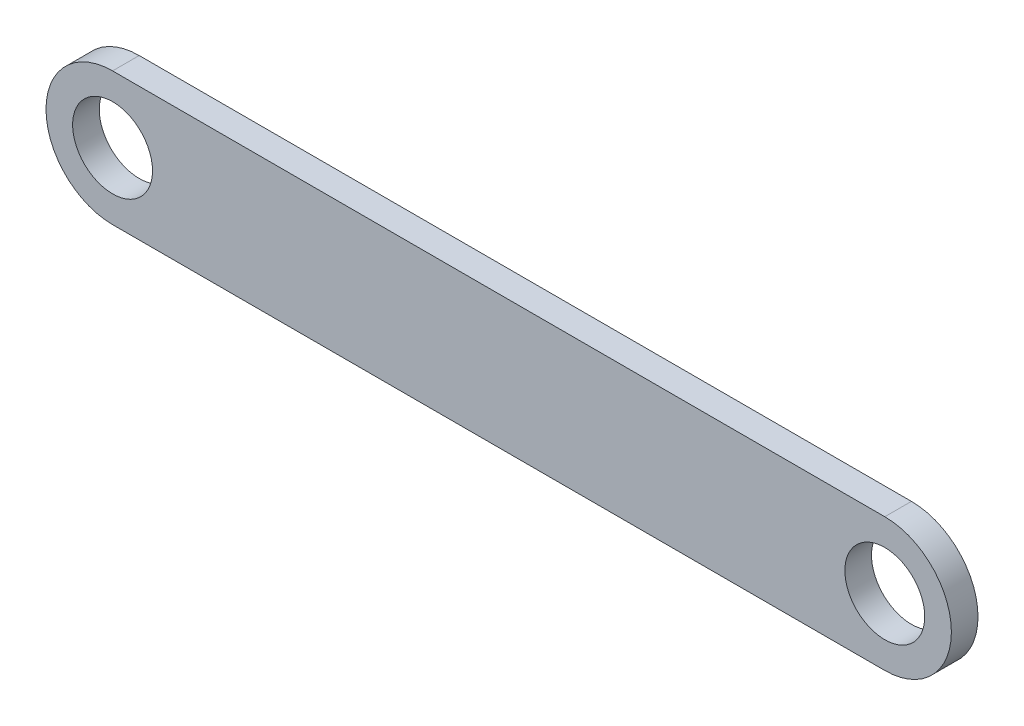
from build123d import *

# Parameters (mm, degrees)
SKETCH1_R           = 7.5
BOSS_EXTRUDE1_DEPTH = 2.5


with BuildPart() as part:
    # Sketch1 → Boss-Extrude1 (new body, symmetric)
    with BuildSketch(Plane.XY):
        with BuildLine():
            Line((0, 12.5), (145, 12.5))
            ThreePointArc((145, 12.5), (157.5, 0), (145, -12.5))
            Line((145, -12.5), (0, -12.5))
            ThreePointArc((0, -12.5), (-12.5, 0), (0, 12.5))
        make_face()
        Circle(SKETCH1_R, mode=Mode.SUBTRACT)
        with Locations((145, 0)):
            Circle(SKETCH1_R, mode=Mode.SUBTRACT)
    extrude(amount=BOSS_EXTRUDE1_DEPTH, both=True)


solid = part.part
